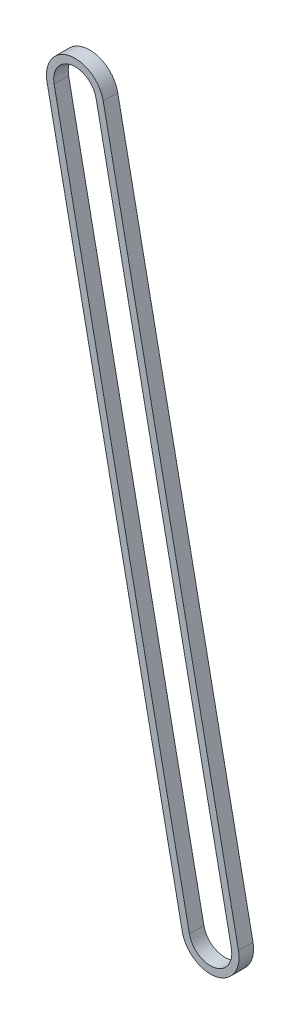
from build123d import *

# Parameters (mm, degrees)
BOSS_EXTRUDE1_DEPTH = 4
CUT_EXTRUDE1_DEPTH  = 4


with BuildPart() as part:
    # Sketch3 → Boss-Extrude1 (new body)
    with BuildSketch(Plane.XY):
        with BuildLine():
            Line((44.988998007, -182.443553074), (7.742974777, 1.567272025))
            ThreePointArc((7.742974777, 1.567272025), (-1.567272025, 7.742974777), (-7.742974777, -1.567272025))
            Line((-7.742974777, -1.567272025), (29.503048453, -185.578097123))
            ThreePointArc((29.503048453, -185.578097123), (38.813295255, -191.753799876), (44.988998007, -182.443553074))
        make_face()
    extrude(amount=BOSS_EXTRUDE1_DEPTH)

    # Sketch4 → Cut-Extrude1 (cut)
    with BuildSketch(Plane.XY.offset(4)):
        with BuildLine():
            Line((43.028751228, -182.840330802), (5.782727998, 1.170494297))
            ThreePointArc((5.782727998, 1.170494297), (-1.170494297, 5.782727998), (-5.782727998, -1.170494297))
            Line((-5.782727998, -1.170494297), (31.463295232, -185.181319396))
            ThreePointArc((31.463295232, -185.181319396), (38.416517527, -189.793553097), (43.028751228, -182.840330802))
        make_face()
    extrude(amount=-CUT_EXTRUDE1_DEPTH, mode=Mode.SUBTRACT)


solid = part.part
